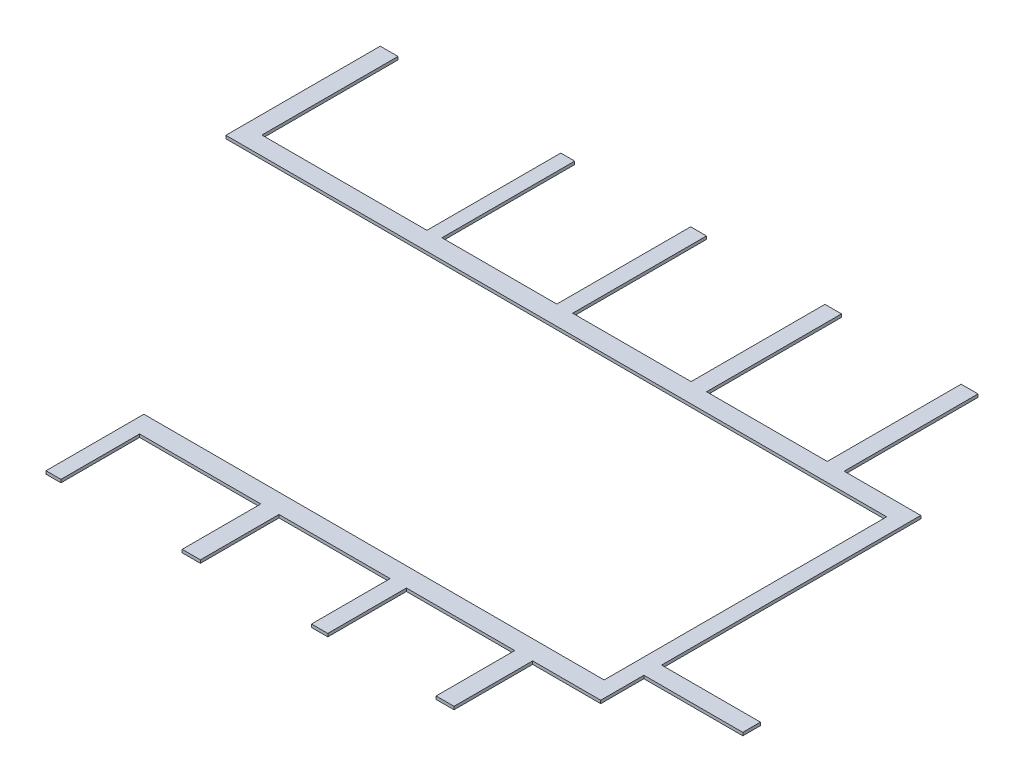
from build123d import *

# Parameters (mm, degrees)
SALIENTE_EXTRUIR1_DEPTH = 20


with BuildPart() as part:
    # Croquis1 → Saliente-Extruir1 (new body)
    with BuildSketch(Plane(origin=(0, 0, 0), x_dir=(1, 0, 0), z_dir=(0, 1, 0))):
        Polygon((-4448.678195779, -7294), (-4448.678195779, -8309), (-503.724981637, -8309), (-104.09646946, -8309), (-104.09646946, -10009), (-104.09646946, -10166.539756835), (-3130.125280174, -10166.539756835), (-3130.125280174, -10810), (-3031.77401608, -10810), (-3031.77401608, -10293.043552141), (-2234.903210462, -10293.043552141), (-2234.903210462, -10810), (-2115.169242354, -10810), (-2115.169242354, -10293.043552141), (-1384.659557399, -10293.043552141), (-1384.659557399, -10810), (-1277.546786748, -10810), (-1277.546786748, -10293.043552141), (-565.360320281, -10293.043552141), (-565.360320281, -10810), (-447.522754169, -10810), (-447.522754169, -10293.043552141), (0, -10293.043552141), (0, -10009), (650, -10009), (650, -9892.960428294), (0, -9892.960428294), (0, -8189), (-503.724981637, -8189), (-503.724981637, -7309), (-614.594937337, -7309), (-614.594937337, -8189), (-1408.216581964, -8189), (-1408.216581964, -7302), (-1516.96854741, -7302), (-1516.96854741, -8182), (-2295.685468291, -8182), (-2295.685468291, -7302), (-2399.823761144, -7302), (-2399.823761144, -8182), (-3154.988725165, -8182), (-3154.988725165, -7309), (-3246.729822708, -7309), (-3246.729822708, -8189), (-4331.805284711, -8189), (-4331.805284711, -7294), align=None)
    extrude(amount=SALIENTE_EXTRUIR1_DEPTH)


solid = part.part
